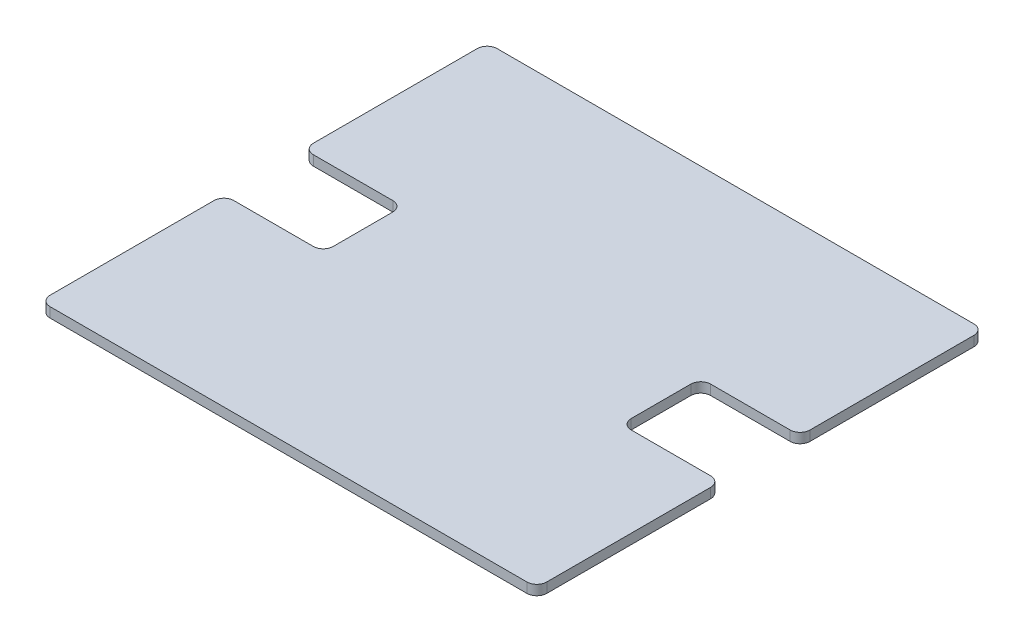
from build123d import *

# Parameters (mm, degrees)
BOSS_EXTRUDE1_DEPTH = 2
FILLET1_R           = 2


with BuildPart() as part:
    # Sketch2 → Boss-Extrude1 (new body)
    with BuildSketch(Plane(origin=(0, 0, 0), x_dir=(1, 0, 0), z_dir=(0, 1, 0))):
        Polygon((-50, 45), (50, 45), (50, 8), (30, 8), (30, -8), (50, -8), (50, -45), (-50, -45), (-50, -8), (-30, -8), (-30, 8), (-50, 8), align=None)
    extrude(amount=BOSS_EXTRUDE1_DEPTH)

    # Fillet1
    fillet1_edges = [part.edges().sort_by_distance(p)[0] for p in [
        (-50, 1, -45),
        (50, 1, -45),
        (50, 1, -8),
        (30, 1, -8),
        (30, 1, 8),
        (50, 1, 8),
        (50, 1, 45),
        (-50, 1, 45),
        (-50, 1, 8),
        (-30, 1, 8),
        (-30, 1, -8),
        (-50, 1, -8),
    ]]
    fillet(fillet1_edges, radius=FILLET1_R)


solid = part.part
